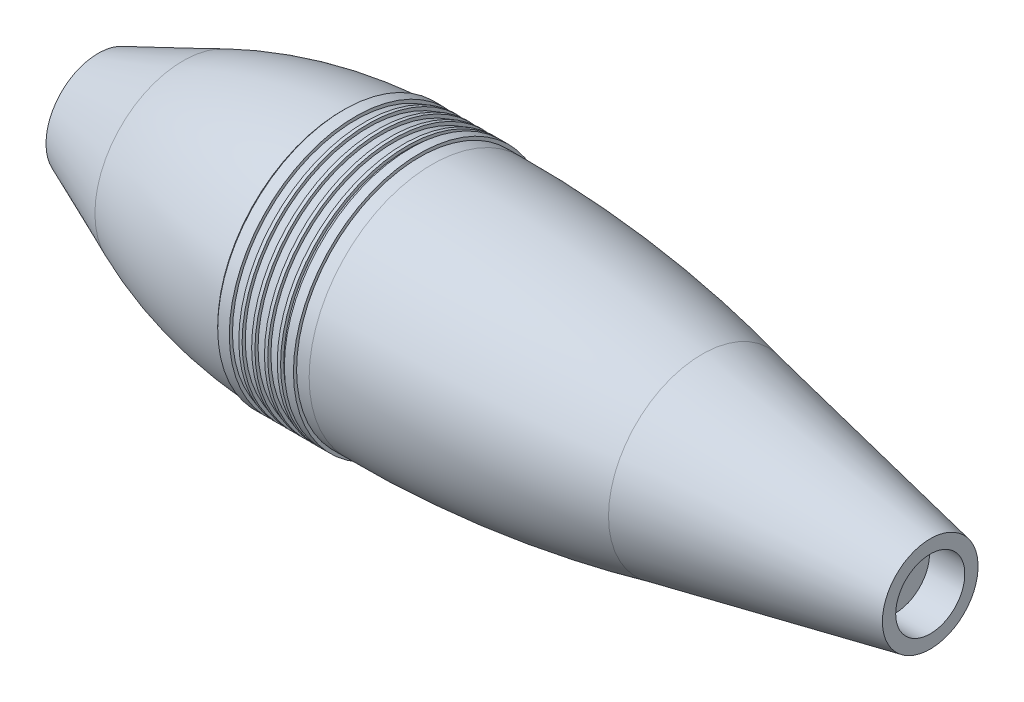
from build123d import *


with BuildPart() as part:
    # Sketch1 → Revolve7 (revolve)
    with BuildSketch(Plane.XY):
        with BuildLine():
            Line((-198.645, 24.89), (-158.065, 42.12))
            ThreePointArc((-158.065, 42.12), (-120.949571992, 54.095027396), (-82.295, 59.27))
            ThreePointArc((-82.295, 59.27), (-81.722815543, 59.697815543), (-81.295, 60.27))
            Line((-81.295, 60.27), (-75.755, 60.27))
            Line((-75.755, 60.27), (-75.755, 58.765))
            Line((-75.755, 58.765), (-71.215, 60.27))
            Line((-71.215, 60.27), (-69.635, 60.27))
            Line((-69.635, 60.27), (-69.635, 58.765))
            Line((-69.635, 58.765), (-65.095, 60.27))
            Line((-65.095, 60.27), (-63.515, 60.27))
            Line((-63.515, 60.27), (-63.515, 58.765))
            Line((-63.515, 58.765), (-58.975, 60.27))
            Line((-58.975, 60.27), (-57.395, 60.27))
            Line((-57.395, 60.27), (-57.395, 58.765))
            Line((-57.395, 58.765), (-52.855, 60.27))
            Line((-52.855, 60.27), (-51.275, 60.27))
            Line((-51.275, 60.27), (-51.275, 58.765))
            Line((-51.275, 58.765), (-49.475, 60.27))
            Line((-49.475, 60.27), (-45.135, 60.27))
            Line((-45.135, 60.27), (-45.135, 58.765))
            Line((-45.135, 58.765), (-44.135, 58.765))
            Line((-44.135, 58.765), (-39.135, 58.765))
            ThreePointArc((-39.135, 58.765), (25.693826597, 55.454514457), (89.705, 44.67))
            Line((89.705, 44.67), (198.645, 22.84))
            Line((198.645, 22.84), (198.645, 16.5))
            Line((198.645, 16.5), (181.815, 16.5))
            Line((181.815, 16.5), (181.815, 0))
            Line((181.815, 0), (171.905, 0))
            Line((171.905, 0), (171.905, 8.615285742))
            ThreePointArc((171.905, 8.615285742), (169.757653906, 14.806878964), (164.237834674, 18.339373482))
            Line((164.237834674, 18.339373482), (89.705, 36.22))
            ThreePointArc((89.705, 36.22), (39.696478516, 43.963471631), (-10.775, 47.63))
            Line((-10.775, 47.63), (-79.995, 47.63))
            ThreePointArc((-79.995, 47.63), (-132.790093523, 40.554253152), (-181.597791569, 19.218913806))
            ThreePointArc((-181.597791569, 19.218913806), (-182.365435036, 18.418408121), (-182.645, 17.34512844))
            Line((-182.645, 17.34512844), (-182.645, 14.5))
            Line((-182.645, 14.5), (-198.645, 14.5))
            Line((-198.645, 14.5), (-198.645, 24.89))
        make_face()
    revolve(axis=Axis((-198.645, 0, 0), (1, 0, 0)))


solid = part.part
